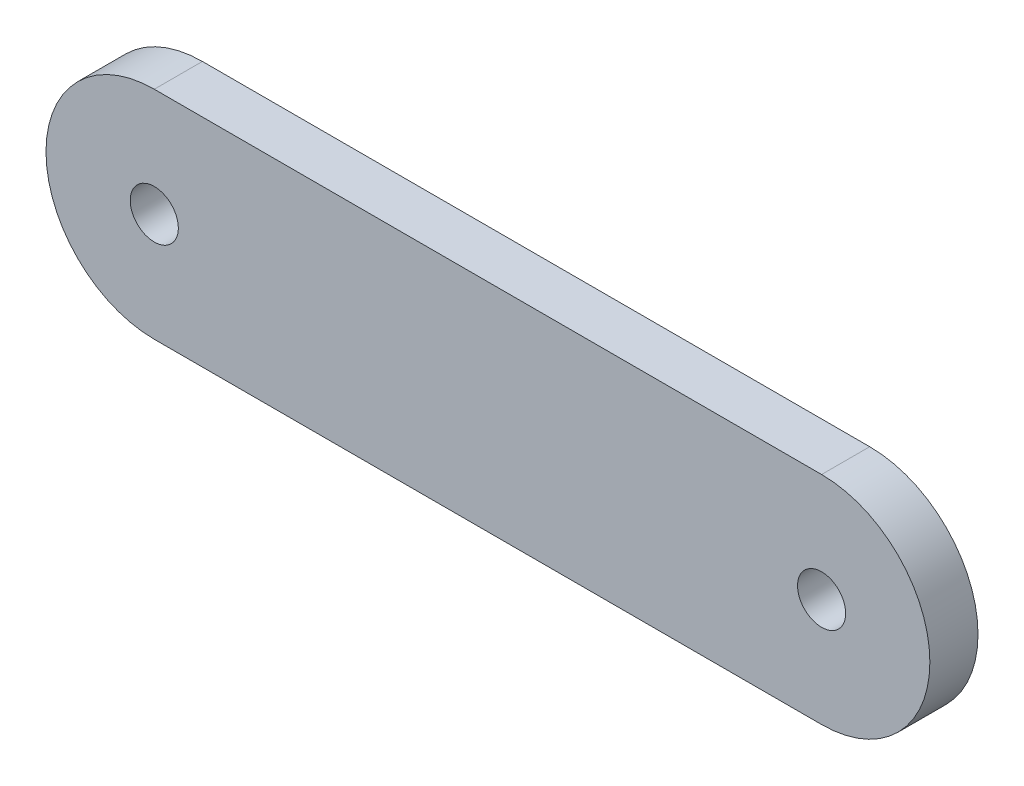
from build123d import *

# Parameters (mm, degrees)
SKETCH1_R           = 0.5
BOSS_EXTRUDE1_DEPTH = 1


with BuildPart() as part:
    # Sketch1 → Boss-Extrude1 (new body)
    with BuildSketch(Plane.XY):
        with BuildLine():
            Line((2.249495034, 2.25), (16.115627007, 2.25))
            ThreePointArc((16.115627007, 2.25), (18.365627007, 0), (16.115627007, -2.25))
            Line((16.115627007, -2.25), (2.249495034, -2.25))
            ThreePointArc((2.249495034, -2.25), (-0.000504966, 0), (2.249495034, 2.25))
        make_face()
        with Locations((2.249495034, 0)):
            Circle(SKETCH1_R, mode=Mode.SUBTRACT)
        with Locations((16.115627007, 0)):
            Circle(SKETCH1_R, mode=Mode.SUBTRACT)
    extrude(amount=BOSS_EXTRUDE1_DEPTH)


solid = part.part
